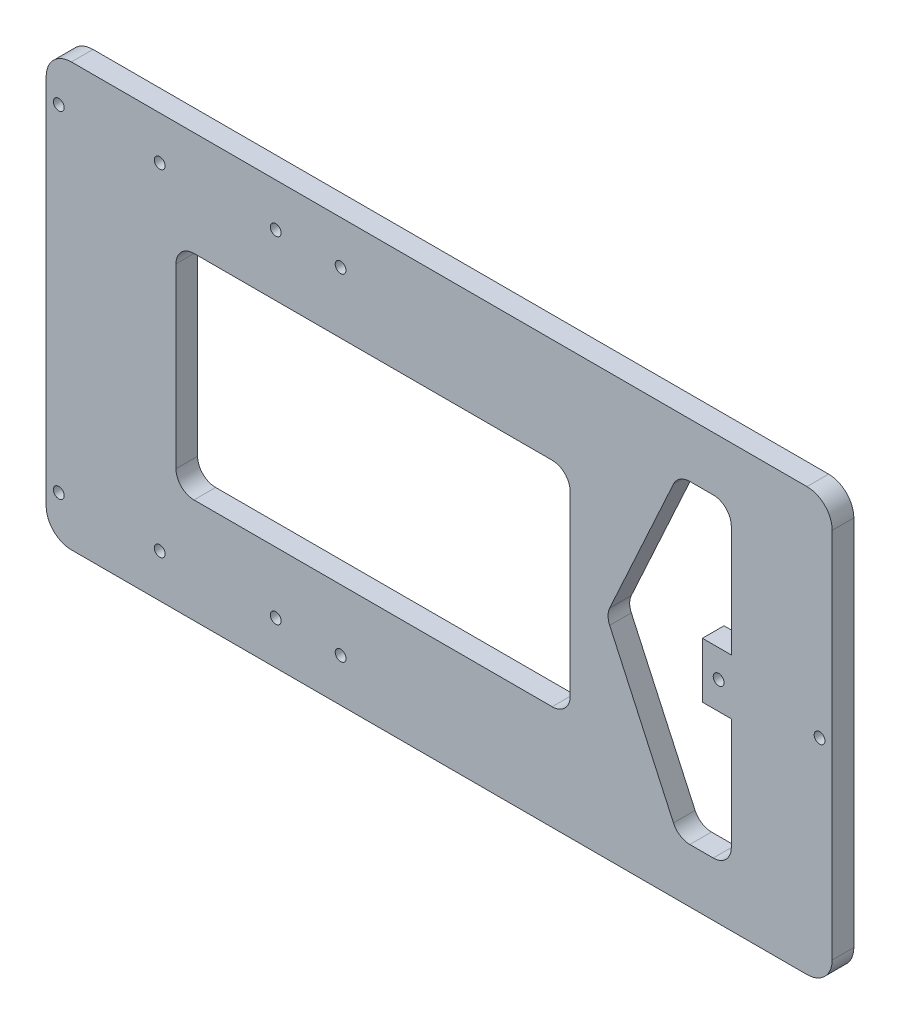
from build123d import *

# Parameters (mm, degrees)
SKETCH1_W           = 218
SKETCH1_H           = 117.2
SKETCH1_R           = 1.5
BOSS_EXTRUDE1_DEPTH = 6
SKETCH2_R           = 1.5
CUT_EXTRUDE1_DEPTH  = 6
FILLET1_R           = 7
SKETCH3_W           = 109.333333333
SKETCH3_H           = 59.2
CUT_EXTRUDE2_DEPTH  = 10
FILLET3_R           = 5
CUT_EXTRUDE3_DEPTH  = 10
FILLET4_R           = 5


with BuildPart() as part:
    # Sketch1 → Boss-Extrude1 (new body)
    with BuildSketch(Plane.XY):
        with Locations((-150.609177744, 197.743600407)):
            Rectangle(SKETCH1_W, SKETCH1_H)
        with Locations((-256.109177744, 244.343600407)):
            Circle(SKETCH1_R, mode=Mode.SUBTRACT)
        with Locations((-256.109177744, 151.143600407)):
            Circle(SKETCH1_R, mode=Mode.SUBTRACT)
        with Locations((-45.109177744, 197.743600407)):
            Circle(SKETCH1_R, mode=Mode.SUBTRACT)
        with Locations((-73.109177744, 197.743600407)):
            Circle(SKETCH1_R, mode=Mode.SUBTRACT)
        with Locations((-228.109177744, 244.343600407)):
            Circle(SKETCH1_R, mode=Mode.SUBTRACT)
        with Locations((-228.109177744, 151.143600407)):
            Circle(SKETCH1_R, mode=Mode.SUBTRACT)
    extrude(amount=BOSS_EXTRUDE1_DEPTH)

    # Sketch2 → Cut-Extrude1 (cut)
    with BuildSketch(Plane.XY.offset(6)):
        with Locations((-195.942511077, 151.143600407)):
            Circle(SKETCH2_R)
        with Locations((-177.942511077, 151.143600407)):
            Circle(SKETCH2_R)
        with Locations((-195.942511077, 244.343600407)):
            Circle(SKETCH2_R)
        with Locations((-177.942511077, 244.343600407)):
            Circle(SKETCH2_R)
    extrude(amount=-CUT_EXTRUDE1_DEPTH, mode=Mode.SUBTRACT)

    # Fillet1
    fillet1_edges = [part.edges().sort_by_distance(p)[0] for p in [
        (-259.609177744, 256.343600407, 3),
        (-41.609177744, 256.343600407, 3),
        (-41.609177744, 139.143600407, 3),
        (-259.609177744, 139.143600407, 3),
    ]]
    fillet(fillet1_edges, radius=FILLET1_R)

    # Sketch3 → Cut-Extrude2 (cut)
    with BuildSketch(Plane(origin=(0, 0, 0), x_dir=(-1, 0, 0), z_dir=(0, 0, -1))):
        with Locations((168.942511078, 197.743600407)):
            Rectangle(SKETCH3_W, SKETCH3_H)
    extrude(amount=-CUT_EXTRUDE2_DEPTH, mode=Mode.SUBTRACT)

    # Fillet3
    fillet3_edges = [part.edges().sort_by_distance(p)[0] for p in [
        (-114.275844411, 168.143600407, 3),
        (-114.275844411, 227.343600407, 3),
        (-223.609177744, 227.343600407, 3),
        (-223.609177744, 168.143600407, 3),
    ]]
    fillet(fillet3_edges, radius=FILLET3_R)

    # Sketch4 → Cut-Extrude3 (cut)
    with BuildSketch(Plane(origin=(0, 0, 0), x_dir=(-1, 0, 0), z_dir=(0, 0, -1))):
        Polygon((84.298987117, 241.343600407), (69.597266226, 241.343600407), (69.597266226, 205.418600407), (77.609177744, 205.418600407), (77.609177744, 190.068600407), (69.597266226, 190.068600407), (69.597266226, 154.143600407), (84.298987117, 154.143600407), (104.275844411, 197.743600407), align=None)
    extrude(amount=-CUT_EXTRUDE3_DEPTH, mode=Mode.SUBTRACT)

    # Fillet4
    fillet4_edges = [part.edges().sort_by_distance(p)[0] for p in [
        (-69.597266226, 241.343600407, 3),
        (-84.298987117, 241.343600407, 3),
        (-104.275844411, 197.743600407, 3),
        (-84.298987117, 154.143600407, 3),
        (-69.597266226, 154.143600407, 3),
    ]]
    fillet(fillet4_edges, radius=FILLET4_R)


solid = part.part
